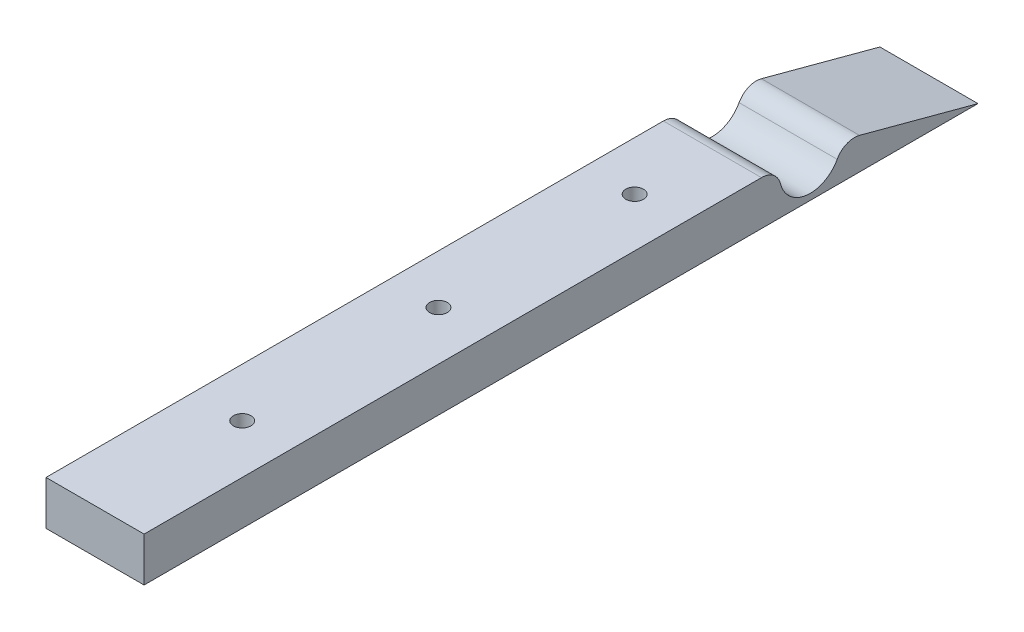
from build123d import *

# Parameters (mm, degrees)
BOSS_EXTRUDE1_DEPTH = 25.4
SKETCH2_R           = 2.286
CUT_EXTRUDE1_DEPTH  = 12.43
CUT_EXTRUDE2_DEPTH  = 6.35


with BuildPart() as part:
    # Sketch1 → Boss-Extrude1 (new body)
    with BuildSketch(Plane(origin=(0, 0, 0), x_dir=(0, 0, -1), z_dir=(1, 0, 0))):
        with BuildLine():
            Line((0, 0), (215.9, 0))
            Line((215.9, 0), (185.220791685, 8.220469092))
            ThreePointArc((185.220791685, 8.220469092), (181.900696214, 7.98102699), (179.441604229, 5.73754018))
            ThreePointArc((179.441604229, 5.73754018), (171.472327537, 1.649943093), (164.7682143, 7.58902439))
            ThreePointArc((164.7682143, 7.58902439), (162.965103566, 10.356285306), (159.841631451, 11.43))
            Line((159.841631451, 11.43), (0, 11.43))
            Line((0, 11.43), (0, 0))
        make_face()
    extrude(amount=BOSS_EXTRUDE1_DEPTH)

    # Sketch2 → Cut-Extrude1 (cut, through all)
    with BuildSketch(Plane.XZ):
        with Locations((12.7, -139.7)):
            Circle(SKETCH2_R)
        with Locations((12.7, -88.9)):
            Circle(SKETCH2_R)
        with Locations((12.7, -38.1)):
            Circle(SKETCH2_R)
    extrude(amount=-CUT_EXTRUDE1_DEPTH, mode=Mode.SUBTRACT)

    # Sketch3 → Cut-Extrude2 (cut)
    with BuildSketch(Plane.XZ):
        Polygon((18.12593783, -139.7), (15.412968915, -135.001), (9.987031085, -135.001), (7.27406217, -139.7), (9.987031085, -144.399), (15.412968915, -144.399), align=None)
        Polygon((18.12593783, -88.9), (15.412968915, -84.201), (9.987031085, -84.201), (7.27406217, -88.9), (9.987031085, -93.599), (15.412968915, -93.599), align=None)
        Polygon((18.12593783, -38.1), (15.412968915, -33.401), (9.987031085, -33.401), (7.27406217, -38.1), (9.987031085, -42.799), (15.412968915, -42.799), align=None)
    extrude(amount=-CUT_EXTRUDE2_DEPTH, mode=Mode.SUBTRACT)


solid = part.part
